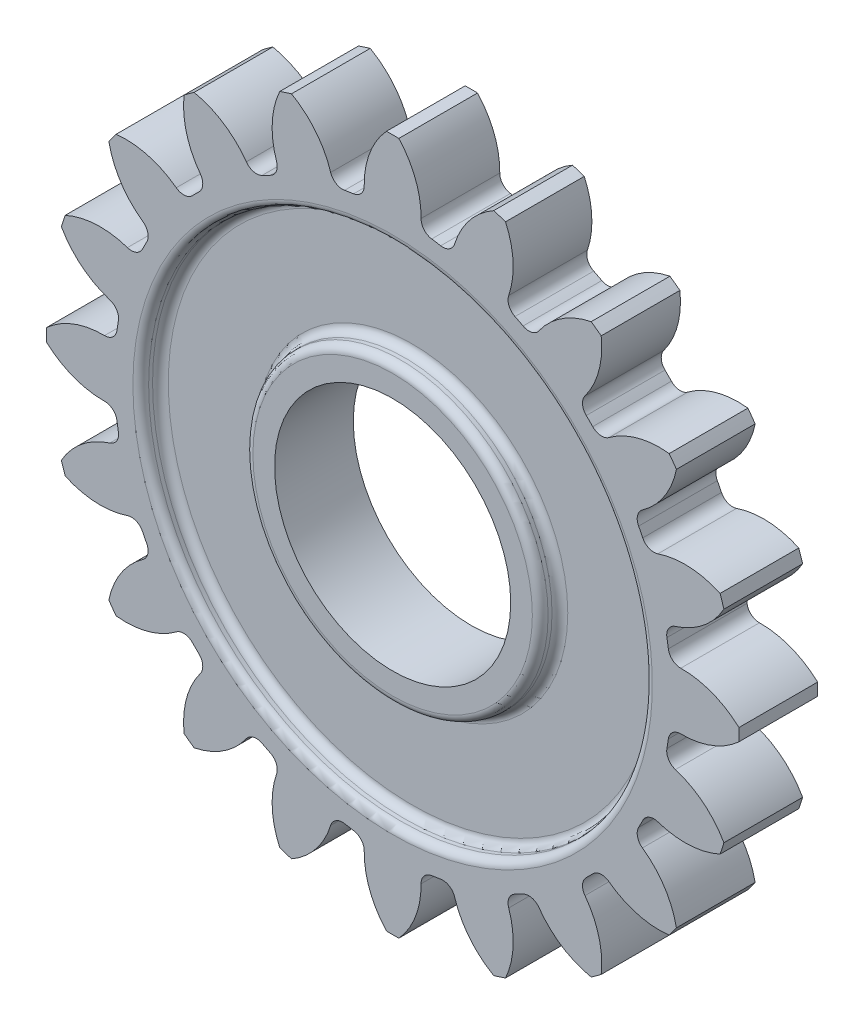
from build123d import *

# Parameters (mm, degrees)
BOSS_EXTRUDE1_DEPTH = 5
CIRPATTERN1_COUNT   = 20
SKETCH5_R           = 17.685841
BOSS_EXTRUDE2_DEPTH = 5
SKETCH6_R           = 7.5
CUT_EXTRUDE1_DEPTH  = 20
SKETCH7_R           = 16
SKETCH7_R_2         = 9.375
CUT_EXTRUDE2_DEPTH  = 1.25
FILLET1_R           = 0.5


with BuildPart() as part:
    # Sketch4 → Boss-Extrude1 (new body)
    with BuildSketch(Plane.XY):
        with BuildLine():
            ThreePointArc((-2.480845609, 17.510978755), (0, -17.685841), (2.480845609, 17.510978755))
            ThreePointArc((2.480845609, 17.510978755), (1.994760478, 17.777407449), (1.805680105, 18.298475214))
            ThreePointArc((1.805680105, 18.298475214), (1.452524206, 20.282385757), (0.393056463, 21.996488507))
            ThreePointArc((0.393056463, 21.996488507), (0, 22), (-0.393056463, 21.996488507))
            ThreePointArc((-0.393056463, 21.996488507), (-1.452524206, 20.282385757), (-1.805680105, 18.298475214))
            ThreePointArc((-1.805680105, 18.298475214), (-1.994760478, 17.777407449), (-2.480845609, 17.510978755))
        make_face()
    extrude(amount=BOSS_EXTRUDE1_DEPTH)


with BuildPart() as cirpattern1_1:
    # CirPattern1: pattern copy
    add(part.part.rotate(Axis((0, 0, 0), (0, 0, 1)), 1 * 360 / CIRPATTERN1_COUNT))


with BuildPart() as cirpattern1_2:
    # CirPattern1: pattern copy
    add(part.part.rotate(Axis((0, 0, 0), (0, 0, 1)), 2 * 360 / CIRPATTERN1_COUNT))


with BuildPart() as cirpattern1_3:
    # CirPattern1: pattern copy
    add(part.part.rotate(Axis((0, 0, 0), (0, 0, 1)), 3 * 360 / CIRPATTERN1_COUNT))


with BuildPart() as cirpattern1_4:
    # CirPattern1: pattern copy
    add(part.part.rotate(Axis((0, 0, 0), (0, 0, 1)), 4 * 360 / CIRPATTERN1_COUNT))


with BuildPart() as cirpattern1_5:
    # CirPattern1: pattern copy
    add(part.part.rotate(Axis((0, 0, 0), (0, 0, 1)), 5 * 360 / CIRPATTERN1_COUNT))


with BuildPart() as cirpattern1_6:
    # CirPattern1: pattern copy
    add(part.part.rotate(Axis((0, 0, 0), (0, 0, 1)), 6 * 360 / CIRPATTERN1_COUNT))


with BuildPart() as cirpattern1_7:
    # CirPattern1: pattern copy
    add(part.part.rotate(Axis((0, 0, 0), (0, 0, 1)), 7 * 360 / CIRPATTERN1_COUNT))


with BuildPart() as cirpattern1_8:
    # CirPattern1: pattern copy
    add(part.part.rotate(Axis((0, 0, 0), (0, 0, 1)), 8 * 360 / CIRPATTERN1_COUNT))


with BuildPart() as cirpattern1_9:
    # CirPattern1: pattern copy
    add(part.part.rotate(Axis((0, 0, 0), (0, 0, 1)), 9 * 360 / CIRPATTERN1_COUNT))


with BuildPart() as cirpattern1_10:
    # CirPattern1: pattern copy
    add(part.part.rotate(Axis((0, 0, 0), (0, 0, 1)), 10 * 360 / CIRPATTERN1_COUNT))


with BuildPart() as cirpattern1_11:
    # CirPattern1: pattern copy
    add(part.part.rotate(Axis((0, 0, 0), (0, 0, 1)), 11 * 360 / CIRPATTERN1_COUNT))


with BuildPart() as cirpattern1_12:
    # CirPattern1: pattern copy
    add(part.part.rotate(Axis((0, 0, 0), (0, 0, 1)), 12 * 360 / CIRPATTERN1_COUNT))


with BuildPart() as cirpattern1_13:
    # CirPattern1: pattern copy
    add(part.part.rotate(Axis((0, 0, 0), (0, 0, 1)), 13 * 360 / CIRPATTERN1_COUNT))


with BuildPart() as cirpattern1_14:
    # CirPattern1: pattern copy
    add(part.part.rotate(Axis((0, 0, 0), (0, 0, 1)), 14 * 360 / CIRPATTERN1_COUNT))


with BuildPart() as cirpattern1_15:
    # CirPattern1: pattern copy
    add(part.part.rotate(Axis((0, 0, 0), (0, 0, 1)), 15 * 360 / CIRPATTERN1_COUNT))


with BuildPart() as cirpattern1_16:
    # CirPattern1: pattern copy
    add(part.part.rotate(Axis((0, 0, 0), (0, 0, 1)), 16 * 360 / CIRPATTERN1_COUNT))


with BuildPart() as cirpattern1_17:
    # CirPattern1: pattern copy
    add(part.part.rotate(Axis((0, 0, 0), (0, 0, 1)), 17 * 360 / CIRPATTERN1_COUNT))


with BuildPart() as cirpattern1_18:
    # CirPattern1: pattern copy
    add(part.part.rotate(Axis((0, 0, 0), (0, 0, 1)), 18 * 360 / CIRPATTERN1_COUNT))


with BuildPart() as cirpattern1_19:
    # CirPattern1: pattern copy
    add(part.part.rotate(Axis((0, 0, 0), (0, 0, 1)), 19 * 360 / CIRPATTERN1_COUNT))


with BuildPart() as part_1:
    add(part.part)

    add(cirpattern1_1.part)  # Boss-Extrude2 merges CirPattern1_1

    add(cirpattern1_2.part)  # Boss-Extrude2 merges CirPattern1_2

    add(cirpattern1_3.part)  # Boss-Extrude2 merges CirPattern1_3

    add(cirpattern1_4.part)  # Boss-Extrude2 merges CirPattern1_4

    add(cirpattern1_5.part)  # Boss-Extrude2 merges CirPattern1_5

    add(cirpattern1_6.part)  # Boss-Extrude2 merges CirPattern1_6

    add(cirpattern1_7.part)  # Boss-Extrude2 merges CirPattern1_7

    add(cirpattern1_8.part)  # Boss-Extrude2 merges CirPattern1_8

    add(cirpattern1_9.part)  # Boss-Extrude2 merges CirPattern1_9

    add(cirpattern1_10.part)  # Boss-Extrude2 merges CirPattern1_10

    add(cirpattern1_11.part)  # Boss-Extrude2 merges CirPattern1_11

    add(cirpattern1_12.part)  # Boss-Extrude2 merges CirPattern1_12

    add(cirpattern1_13.part)  # Boss-Extrude2 merges CirPattern1_13

    add(cirpattern1_14.part)  # Boss-Extrude2 merges CirPattern1_14

    add(cirpattern1_15.part)  # Boss-Extrude2 merges CirPattern1_15

    add(cirpattern1_16.part)  # Boss-Extrude2 merges CirPattern1_16

    add(cirpattern1_17.part)  # Boss-Extrude2 merges CirPattern1_17

    add(cirpattern1_18.part)  # Boss-Extrude2 merges CirPattern1_18

    add(cirpattern1_19.part)  # Boss-Extrude2 merges CirPattern1_19
    # Sketch5 → Boss-Extrude2 (add)
    with BuildSketch(Plane.XY.offset(5)):
        Circle(SKETCH5_R)
    extrude(amount=-BOSS_EXTRUDE2_DEPTH)

    # Sketch6 → Cut-Extrude1 (cut)
    with BuildSketch(Plane.XY.offset(5)):
        Circle(SKETCH6_R)
    extrude(amount=-CUT_EXTRUDE1_DEPTH, mode=Mode.SUBTRACT)

    # Sketch7 → Cut-Extrude2 (cut)
    with BuildSketch(Plane.XY.offset(5)):
        Circle(SKETCH7_R)
        Circle(SKETCH7_R_2, mode=Mode.SUBTRACT)
    cut_extrude2 = extrude(amount=-CUT_EXTRUDE2_DEPTH, mode=Mode.SUBTRACT)

    # Mirror1: Cut-Extrude2 across plane
    add(cut_extrude2.mirror(Plane.XY.offset(2.5)), mode=Mode.SUBTRACT)

    # Fillet1
    fillet1_edges = [part_1.edges().sort_by_distance(p)[0] for p in [
        (-16, 0, 3.75),
        (-9.375, 0, 3.75),
        (-16, 0, 5),
        (-9.375, 0, 5),
        (-16, 0, 1.25),
        (-9.375, 0, 0),
        (-16, 0, 0),
        (-9.375, 0, 1.25),
    ]]
    fillet(fillet1_edges, radius=FILLET1_R)


solid = part_1.part
